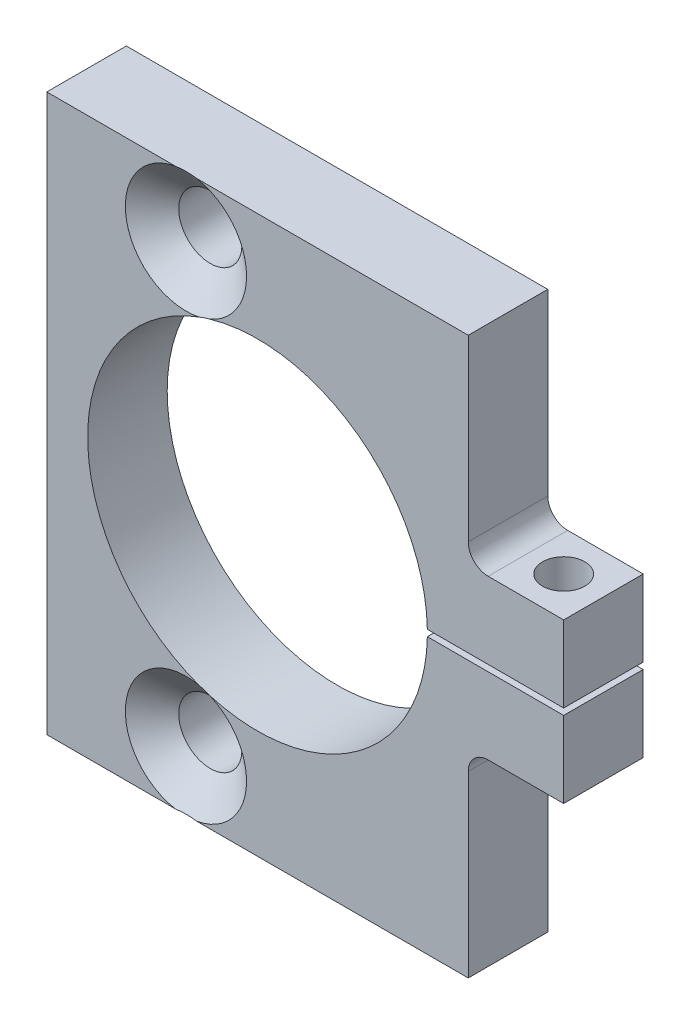
from build123d import *

# Parameters (mm, degrees)
SKETCH1_W                                           = 82.55
SKETCH1_H                                           = 88.9
EXTRUDE1_DEPTH                                      = 12.7
SKETCH2_R                                           = 27.1272
EXTRUDE2_DEPTH                                      = 13.7
SKETCH3_W                                           = 28.468633454
SKETCH3_H                                           = 1.016
EXTRUDE3_DEPTH                                      = 13.7
F_1_4_CLEARANCE_HOLE1_D                             = 6.7564
CSK_FOR_3_8_FLAT_HEAD_MACHINE_SCREW_100_D           = 10.0838
CSK_FOR_3_8_FLAT_HEAD_MACHINE_SCREW_100_CSINK_D     = 19.3548
CSK_FOR_3_8_FLAT_HEAD_MACHINE_SCREW_100_CSINK_ANGLE = 100
SKETCH10_W                                          = 15.24
SKETCH10_H                                          = 31.75
EXTRUDE4_DEPTH                                      = 13.7000001
FILLET1_R                                           = 3.175


with BuildPart() as part:
    # Sketch1 → Extrude1 (new body)
    with BuildSketch(Plane.XY):
        Rectangle(SKETCH1_W, SKETCH1_H)
    extrude(amount=EXTRUDE1_DEPTH)

    # Sketch2 → Extrude2 (cut, through all)
    with BuildSketch(Plane.XY.offset(12.7)):
        with Locations((-7.62, 0)):
            Circle(SKETCH2_R)
    extrude(amount=-EXTRUDE2_DEPTH, mode=Mode.SUBTRACT)

    # Sketch3 → Extrude3 (cut, through all)
    with BuildSketch(Plane.XY.offset(12.7)):
        with Locations((30.3911, 0)):
            Rectangle(SKETCH3_W, SKETCH3_H)
    extrude(amount=-EXTRUDE3_DEPTH, mode=Mode.SUBTRACT)

    # 1/4 Clearance Hole1 (through all)
    with Locations(Plane(origin=(34.925, 44.45, 6.35), x_dir=(0, 0, 1), z_dir=(0, 1, 0))):
        with Locations((0, 0)):
            Hole(F_1_4_CLEARANCE_HOLE1_D / 2)

    # CSK for 3/8 Flat Head Machine Screw (100)1 (through all)
    with Locations(Plane(origin=(-19.05, 34.925, 12.7), x_dir=(1, 0, 0), z_dir=(0, 0, 1))):
        with Locations((0, 0)):
            csk_for_3_8_flat_head_machine_screw_100 = CounterSinkHole(CSK_FOR_3_8_FLAT_HEAD_MACHINE_SCREW_100_D / 2, CSK_FOR_3_8_FLAT_HEAD_MACHINE_SCREW_100_CSINK_D / 2, counter_sink_angle=CSK_FOR_3_8_FLAT_HEAD_MACHINE_SCREW_100_CSINK_ANGLE)

    # Mirror1: CSK for 3/8 Flat Head Machine Screw (100)1 across plane
    add(csk_for_3_8_flat_head_machine_screw_100.mirror(Plane.ZX), mode=Mode.SUBTRACT)

    # Sketch10 → Extrude4 (cut, through all)
    with BuildSketch(Plane.XY.offset(12.7)):
        with Locations((33.655, 28.575)):
            Rectangle(SKETCH10_W, SKETCH10_H)
    extrude4 = extrude(amount=-EXTRUDE4_DEPTH, mode=Mode.SUBTRACT)

    # Mirror2: Extrude4 across plane
    add(extrude4.mirror(Plane.ZX), mode=Mode.SUBTRACT)

    # Fillet1
    fillet1_edges = [part.edges().sort_by_distance(p)[0] for p in [
        (26.035, 12.7, 6.35),
        (26.035, -12.7, 6.35),
    ]]
    fillet(fillet1_edges, radius=FILLET1_R)


solid = part.part
